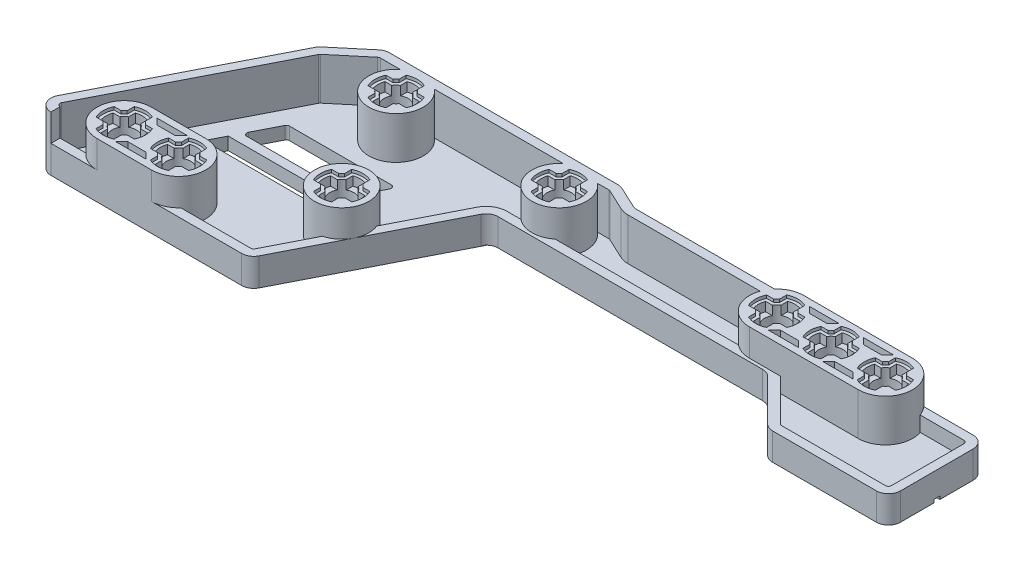
from build123d import *

# Parameters (mm, degrees)
SKETCH2_R           = 2
BOSS_EXTRUDE1_DEPTH = 9
CUT_EXTRUDE1_DEPTH  = 2
CUT_EXTRUDE3_DEPTH  = 0.5
LPATTERN1_COUNT     = 3
LPATTERN1_PITCH     = 9
CUT_EXTRUDE4_DEPTH  = 3
SKETCH6_R           = 4.5
SKETCH6_R_2         = 2
BOSS_EXTRUDE2_DEPTH = 4.5
CUT_EXTRUDE5_DEPTH  = 2
CUT_EXTRUDE6_DEPTH  = 0.5
SKETCH10_R          = 4.5
SKETCH10_R_2        = 2
BOSS_EXTRUDE3_DEPTH = 4.5
CUT_EXTRUDE7_DEPTH  = 2
CUT_EXTRUDE8_DEPTH  = 0.5
SKETCH13_R          = 4.5
SKETCH13_R_2        = 2
BOSS_EXTRUDE4_DEPTH = 4.5
CUT_EXTRUDE9_DEPTH  = 2
CUT_EXTRUDE10_DEPTH = 0.5
SKETCH16_R          = 2
BOSS_EXTRUDE5_DEPTH = 4.5
CUT_EXTRUDE11_DEPTH = 2
CUT_EXTRUDE12_DEPTH = 0.5
SKETCH19_R          = 2
BOSS_EXTRUDE6_DEPTH = 2
FILLET1_R           = 2
EXTRUDE_THIN1_DEPTH = 2.5
EXTRUDE_THIN2_DEPTH = 7
CUT_EXTRUDE13_DEPTH = 3
CUT_EXTRUDE14_DEPTH = 2
SKETCH25_R          = 2.5
CUT_EXTRUDE15_DEPTH = 0.5
CUT_EXTRUDE18_DEPTH = 0.5
FILLET2_R           = 0.5
SKETCH28_R          = 2.5
BOSS_EXTRUDE7_DEPTH = 0.1


with BuildPart() as part:
    # Sketch2 → Boss-Extrude1 (new body)
    with BuildSketch(Plane(origin=(0, 0, 0), x_dir=(1, 0, 0), z_dir=(0, 1, 0))):
        with BuildLine():
            Line((-9, 4.5), (9, 4.5))
            ThreePointArc((9, 4.5), (13.5, 0), (9, -4.5))
            Line((9, -4.5), (-9, -4.5))
            ThreePointArc((-9, -4.5), (-13.5, 0), (-9, 4.5))
        make_face()
        with Locations(Location((0, 0, 0), (0, 0, 270))):
            Circle(SKETCH2_R, mode=Mode.SUBTRACT)
        with Locations(Location((-9, 0, 0), (0, 0, 270))):
            Circle(SKETCH2_R, mode=Mode.SUBTRACT)
        with Locations(Location((9, 0, 0), (0, 0, 270))):
            Circle(SKETCH2_R, mode=Mode.SUBTRACT)
    extrude(amount=BOSS_EXTRUDE1_DEPTH)

    # Sketch3 → Cut-Extrude1 (cut)
    with BuildSketch(Plane(origin=(0, 9, 0), x_dir=(1, 0, 0), z_dir=(0, 1, 0))):
        with BuildLine():
            Line((-10.732050808, 1), (-11.828427125, 1))
            ThreePointArc((-11.828427125, 1), (-12, 0), (-11.828427125, -1))
            Line((-11.828427125, -1), (-10.732050808, -1))
            ThreePointArc((-10.732050808, -1), (-11, 0), (-10.732050808, 1))
        make_face()
        with BuildLine():
            Line((-10, -1.732050808), (-10, -2.828427125))
            ThreePointArc((-10, -2.828427125), (-9, -3), (-8, -2.828427125))
            Line((-8, -2.828427125), (-8, -1.732050808))
            ThreePointArc((-8, -1.732050808), (-9, -2), (-10, -1.732050808))
        make_face()
        with BuildLine():
            Line((-8, 1.732050808), (-8, 2.828427125))
            ThreePointArc((-8, 2.828427125), (-9, 3), (-10, 2.828427125))
            Line((-10, 2.828427125), (-10, 1.732050808))
            ThreePointArc((-10, 1.732050808), (-9, 2), (-8, 1.732050808))
        make_face()
        with BuildLine():
            Line((-7.267949192, -1), (-6.171572875, -1))
            ThreePointArc((-6.171572875, -1), (-6, 0), (-6.171572875, 1))
            Line((-6.171572875, 1), (-7.267949192, 1))
            ThreePointArc((-7.267949192, 1), (-7, 0), (-7.267949192, -1))
        make_face()
    cut_extrude1 = extrude(amount=-CUT_EXTRUDE1_DEPTH, mode=Mode.SUBTRACT)

    # Sketch4 → Cut-Extrude3 (cut)
    with BuildSketch(Plane(origin=(0, 9, 0), x_dir=(1, 0, 0), z_dir=(0, 1, 0))):
        with BuildLine():
            Line((-11, 1.5), (-12.16227766, 1.5))
            ThreePointArc((-12.16227766, 1.5), (-12.5, 0), (-12.16227766, -1.5))
            Line((-12.16227766, -1.5), (-11, -1.5))
            ThreePointArc((-11, -1.5), (-10.767766953, -1.767766953), (-10.5, -2))
            Line((-10.5, -2), (-10.5, -3.16227766))
            ThreePointArc((-10.5, -3.16227766), (-9, -3.5), (-7.5, -3.16227766))
            Line((-7.5, -3.16227766), (-7.5, -2))
            ThreePointArc((-7.5, -2), (-7.232233047, -1.767766953), (-7, -1.5))
            Line((-7, -1.5), (-5.83772234, -1.5))
            ThreePointArc((-5.83772234, -1.5), (-5.5, 0), (-5.83772234, 1.5))
            Line((-5.83772234, 1.5), (-7, 1.5))
            ThreePointArc((-7, 1.5), (-7.232233047, 1.767766953), (-7.5, 2))
            Line((-7.5, 2), (-7.5, 3.16227766))
            ThreePointArc((-7.5, 3.16227766), (-9, 3.5), (-10.5, 3.16227766))
            Line((-10.5, 3.16227766), (-10.5, 2))
            ThreePointArc((-10.5, 2), (-10.767766953, 1.767766953), (-11, 1.5))
        make_face()
    cut_extrude3 = extrude(amount=-CUT_EXTRUDE3_DEPTH, mode=Mode.SUBTRACT)

    # LPattern1: Cut-Extrude1, Cut-Extrude3 ×3
    with Locations(*[(i * LPATTERN1_PITCH, 0, 0) for i in range(1, LPATTERN1_COUNT)]):
        add(cut_extrude1, mode=Mode.SUBTRACT)
        add(cut_extrude3, mode=Mode.SUBTRACT)

    # Sketch5 → Cut-Extrude4 (cut)
    with BuildSketch(Plane(origin=(0, 9, 0), x_dir=(1, 0, 0), z_dir=(0, 1, 0))):
        Polygon((-7.003004547, 3.4), (-2.003004547, 3.4), (-3.003004547, 2.4), (-6.003004547, 2.4), align=None)
        Polygon((-3.003004547, -2.4), (-6.003004547, -2.4), (-7.003004547, -3.4), (-2.003004547, -3.4), align=None)
        Polygon((2.003004547, -3.4), (3.003004547, -2.4), (6.003004547, -2.4), (7.003004547, -3.4), align=None)
        Polygon((3.003004547, 2.4), (6.003004547, 2.4), (7.003004547, 3.4), (2.003004547, 3.4), align=None)
    extrude(amount=-CUT_EXTRUDE4_DEPTH, mode=Mode.SUBTRACT)



with BuildPart() as body_2:
    # Sketch6 → Boss-Extrude2 (new, symmetric)
    with BuildSketch(Plane(origin=(0, 4.5, 0), x_dir=(1, 0, 0), z_dir=(0, 1, 0))):
        with Locations(Location((-45, 0, 0), (0, 0, 270))):
            Circle(SKETCH6_R)
        with Locations(Location((-45, 0, 0), (0, 0, 270))):
            Circle(SKETCH6_R_2, mode=Mode.SUBTRACT)
    extrude(amount=BOSS_EXTRUDE2_DEPTH, both=True)

    # Sketch8 → Cut-Extrude5 (cut)
    with BuildSketch(Plane(origin=(0, 9, 0), x_dir=(1, 0, 0), z_dir=(0, 1, 0))):
        with BuildLine():
            Line((-44, 2.828427125), (-46, 2.828427125))
            Line((-46, 2.828427125), (-46, 1.732050808))
            ThreePointArc((-46, 1.732050808), (-45, 2), (-44, 1.732050808))
            Line((-44, 1.732050808), (-44, 2.828427125))
        make_face()
        with BuildLine():
            Line((-46, -1.732050808), (-46, -2.828427125))
            Line((-46, -2.828427125), (-44, -2.828427125))
            Line((-44, -2.828427125), (-44, -1.732050808))
            ThreePointArc((-44, -1.732050808), (-45, -2), (-46, -1.732050808))
        make_face()
        with BuildLine():
            Line((-42.171572875, -1), (-42.171572875, 1))
            Line((-42.171572875, 1), (-43.267949192, 1))
            ThreePointArc((-43.267949192, 1), (-43.068148347, 0.51763809), (-43, 0))
            ThreePointArc((-43, 0), (-43.068148347, -0.51763809), (-43.267949192, -1))
            Line((-43.267949192, -1), (-42.171572875, -1))
        make_face()
        with BuildLine():
            Line((-46.732050808, 1), (-47.828427125, 1))
            Line((-47.828427125, 1), (-47.828427125, -1))
            Line((-47.828427125, -1), (-46.732050808, -1))
            ThreePointArc((-46.732050808, -1), (-47, 0), (-46.732050808, 1))
        make_face()
        with BuildLine():
            Line((-47.828427125, -1), (-47.828427125, 1))
            ThreePointArc((-47.828427125, 1), (-48, 0), (-47.828427125, -1))
        make_face()
        with BuildLine():
            ThreePointArc((-44, 2.828427125), (-45, 3), (-46, 2.828427125))
            Line((-46, 2.828427125), (-44, 2.828427125))
        make_face()
        with BuildLine():
            ThreePointArc((-42, 0), (-42.043204321, 0.507305936), (-42.171572875, 1))
            Line((-42.171572875, 1), (-42.171572875, -1))
            ThreePointArc((-42.171572875, -1), (-42.043204321, -0.507305936), (-42, 0))
        make_face()
        with BuildLine():
            Line((-44, -2.828427125), (-46, -2.828427125))
            ThreePointArc((-46, -2.828427125), (-45, -3), (-44, -2.828427125))
        make_face()
    extrude(amount=-CUT_EXTRUDE5_DEPTH, mode=Mode.SUBTRACT)

    # Sketch9 → Cut-Extrude6 (cut)
    with BuildSketch(Plane(origin=(0, 9, 0), x_dir=(1, 0, 0), z_dir=(0, 1, 0))):
        with BuildLine():
            Line((-43, -1.5), (-41.83772234, -1.5))
            ThreePointArc((-41.83772234, -1.5), (-41.5, 0), (-41.83772234, 1.5))
            Line((-41.83772234, 1.5), (-43, 1.5))
            ThreePointArc((-43, 1.5), (-43.232233047, 1.767766953), (-43.5, 2))
            Line((-43.5, 2), (-43.5, 3.16227766))
            ThreePointArc((-43.5, 3.16227766), (-45, 3.5), (-46.5, 3.16227766))
            Line((-46.5, 3.16227766), (-46.5, 2))
            ThreePointArc((-46.5, 2), (-46.767766953, 1.767766953), (-47, 1.5))
            Line((-47, 1.5), (-48.16227766, 1.5))
            ThreePointArc((-48.16227766, 1.5), (-48.5, 0), (-48.16227766, -1.5))
            Line((-48.16227766, -1.5), (-47, -1.5))
            ThreePointArc((-47, -1.5), (-46.767766953, -1.767766953), (-46.5, -2))
            Line((-46.5, -2), (-46.5, -3.16227766))
            ThreePointArc((-46.5, -3.16227766), (-45, -3.5), (-43.5, -3.16227766))
            Line((-43.5, -3.16227766), (-43.5, -2))
            ThreePointArc((-43.5, -2), (-43.232233047, -1.767766953), (-43, -1.5))
        make_face()
    extrude(amount=-CUT_EXTRUDE6_DEPTH, mode=Mode.SUBTRACT)


with BuildPart() as body_3:
    # Sketch10 → Boss-Extrude3 (new, symmetric)
    with BuildSketch(Plane(origin=(0, 4.5, 0), x_dir=(1, 0, 0), z_dir=(0, 1, 0))):
        with Locations(Location((-72, 0, 0), (0, 0, 270))):
            Circle(SKETCH10_R)
        with Locations(Location((-72, 0, 0), (0, 0, 270))):
            Circle(SKETCH10_R_2, mode=Mode.SUBTRACT)
    extrude(amount=BOSS_EXTRUDE3_DEPTH, both=True)

    # Sketch11 → Cut-Extrude7 (cut)
    with BuildSketch(Plane(origin=(0, 9, 0), x_dir=(1, 0, 0), z_dir=(0, 1, 0))):
        with BuildLine():
            Line((-71, 2.828427125), (-73, 2.828427125))
            Line((-73, 2.828427125), (-73, 1.732050808))
            ThreePointArc((-73, 1.732050808), (-72, 2), (-71, 1.732050808))
            Line((-71, 1.732050808), (-71, 2.828427125))
        make_face()
        with BuildLine():
            ThreePointArc((-71, 2.828427125), (-72, 3), (-73, 2.828427125))
            Line((-73, 2.828427125), (-71, 2.828427125))
        make_face()
        with BuildLine():
            Line((-70.267949192, -1), (-69.171572875, -1))
            Line((-69.171572875, -1), (-69.171572875, 1))
            Line((-69.171572875, 1), (-70.267949192, 1))
            ThreePointArc((-70.267949192, 1), (-70.068148347, 0.51763809), (-70, 0))
            ThreePointArc((-70, 0), (-70.068148347, -0.51763809), (-70.267949192, -1))
        make_face()
        with BuildLine():
            Line((-69.171572875, 1), (-69.171572875, -1))
            ThreePointArc((-69.171572875, -1), (-69.043204321, -0.507305936), (-69, 0))
            ThreePointArc((-69, 0), (-69.043204321, 0.507305936), (-69.171572875, 1))
        make_face()
        with BuildLine():
            Line((-73, -1.732050808), (-73, -2.828427125))
            Line((-73, -2.828427125), (-71, -2.828427125))
            Line((-71, -2.828427125), (-71, -1.732050808))
            ThreePointArc((-71, -1.732050808), (-72, -2), (-73, -1.732050808))
        make_face()
        with BuildLine():
            Line((-71, -2.828427125), (-73, -2.828427125))
            ThreePointArc((-73, -2.828427125), (-72, -3), (-71, -2.828427125))
        make_face()
        with BuildLine():
            Line((-74.828427125, 1), (-74.828427125, -1))
            Line((-74.828427125, -1), (-73.732050808, -1))
            ThreePointArc((-73.732050808, -1), (-74, 0), (-73.732050808, 1))
            Line((-73.732050808, 1), (-74.828427125, 1))
        make_face()
        with BuildLine():
            ThreePointArc((-74.828427125, 1), (-75, 0), (-74.828427125, -1))
            Line((-74.828427125, -1), (-74.828427125, 1))
        make_face()
    extrude(amount=-CUT_EXTRUDE7_DEPTH, mode=Mode.SUBTRACT)

    # Sketch12 → Cut-Extrude8 (cut)
    with BuildSketch(Plane(origin=(0, 9, 0), x_dir=(1, 0, 0), z_dir=(0, 1, 0))):
        with BuildLine():
            Line((-75.16227766, -1.5), (-74, -1.5))
            ThreePointArc((-74, -1.5), (-73.767766953, -1.767766953), (-73.5, -2))
            Line((-73.5, -2), (-73.5, -3.16227766))
            ThreePointArc((-73.5, -3.16227766), (-72, -3.5), (-70.5, -3.16227766))
            Line((-70.5, -3.16227766), (-70.5, -2))
            ThreePointArc((-70.5, -2), (-70.232233047, -1.767766953), (-70, -1.5))
            Line((-70, -1.5), (-68.83772234, -1.5))
            ThreePointArc((-68.83772234, -1.5), (-68.5, 0), (-68.83772234, 1.5))
            Line((-68.83772234, 1.5), (-70, 1.5))
            ThreePointArc((-70, 1.5), (-70.232233047, 1.767766953), (-70.5, 2))
            Line((-70.5, 2), (-70.5, 3.16227766))
            ThreePointArc((-70.5, 3.16227766), (-72, 3.5), (-73.5, 3.16227766))
            Line((-73.5, 3.16227766), (-73.5, 2))
            ThreePointArc((-73.5, 2), (-73.767766953, 1.767766953), (-74, 1.5))
            Line((-74, 1.5), (-75.16227766, 1.5))
            ThreePointArc((-75.16227766, 1.5), (-75.5, 0), (-75.16227766, -1.5))
        make_face()
    extrude(amount=-CUT_EXTRUDE8_DEPTH, mode=Mode.SUBTRACT)


with BuildPart() as body_4:
    # Sketch13 → Boss-Extrude4 (new, symmetric)
    with BuildSketch(Plane(origin=(0, 4.5, 0), x_dir=(1, 0, 0), z_dir=(0, 1, 0))):
        with Locations(Location((-63, -18, 0), (0, 0, 270))):
            Circle(SKETCH13_R)
        with Locations(Location((-63, -18, 0), (0, 0, 270))):
            Circle(SKETCH13_R_2, mode=Mode.SUBTRACT)
    extrude(amount=BOSS_EXTRUDE4_DEPTH, both=True)

    # Sketch14 → Cut-Extrude9 (cut)
    with BuildSketch(Plane(origin=(0, 9, 0), x_dir=(1, 0, 0), z_dir=(0, 1, 0))):
        with BuildLine():
            Line((-62, -15.171572875), (-64, -15.171572875))
            Line((-64, -15.171572875), (-64, -16.267949192))
            ThreePointArc((-64, -16.267949192), (-63, -16), (-62, -16.267949192))
            Line((-62, -16.267949192), (-62, -15.171572875))
        make_face()
        with BuildLine():
            ThreePointArc((-62, -15.171572875), (-63, -15), (-64, -15.171572875))
            Line((-64, -15.171572875), (-62, -15.171572875))
        make_face()
        with BuildLine():
            Line((-61.267949192, -19), (-60.171572875, -19))
            Line((-60.171572875, -19), (-60.171572875, -17))
            Line((-60.171572875, -17), (-61.267949192, -17))
            ThreePointArc((-61.267949192, -17), (-61.068148347, -17.48236191), (-61, -18))
            ThreePointArc((-61, -18), (-61.068148347, -18.51763809), (-61.267949192, -19))
        make_face()
        with BuildLine():
            Line((-60.171572875, -17), (-60.171572875, -19))
            ThreePointArc((-60.171572875, -19), (-60.043204321, -18.507305936), (-60, -18))
            ThreePointArc((-60, -18), (-60.043204321, -17.492694064), (-60.171572875, -17))
        make_face()
        with BuildLine():
            Line((-64, -19.732050808), (-64, -20.828427125))
            Line((-64, -20.828427125), (-62, -20.828427125))
            Line((-62, -20.828427125), (-62, -19.732050808))
            ThreePointArc((-62, -19.732050808), (-63, -20), (-64, -19.732050808))
        make_face()
        with BuildLine():
            Line((-62, -20.828427125), (-64, -20.828427125))
            ThreePointArc((-64, -20.828427125), (-63, -21), (-62, -20.828427125))
        make_face()
        with BuildLine():
            Line((-65.828427125, -17), (-65.828427125, -19))
            Line((-65.828427125, -19), (-64.732050808, -19))
            ThreePointArc((-64.732050808, -19), (-65, -18), (-64.732050808, -17))
            Line((-64.732050808, -17), (-65.828427125, -17))
        make_face()
        with BuildLine():
            ThreePointArc((-65.828427125, -17), (-66, -18), (-65.828427125, -19))
            Line((-65.828427125, -19), (-65.828427125, -17))
        make_face()
    extrude(amount=-CUT_EXTRUDE9_DEPTH, mode=Mode.SUBTRACT)

    # Sketch15 → Cut-Extrude10 (cut)
    with BuildSketch(Plane(origin=(0, 9, 0), x_dir=(1, 0, 0), z_dir=(0, 1, 0))):
        with BuildLine():
            Line((-59.83772234, -16.5), (-61, -16.5))
            ThreePointArc((-61, -16.5), (-61.232233047, -16.232233047), (-61.5, -16))
            Line((-61.5, -16), (-61.5, -14.83772234))
            ThreePointArc((-61.5, -14.83772234), (-63, -14.5), (-64.5, -14.83772234))
            Line((-64.5, -14.83772234), (-64.5, -16))
            ThreePointArc((-64.5, -16), (-64.767766953, -16.232233047), (-65, -16.5))
            Line((-65, -16.5), (-66.16227766, -16.5))
            ThreePointArc((-66.16227766, -16.5), (-66.5, -18), (-66.16227766, -19.5))
            Line((-66.16227766, -19.5), (-65, -19.5))
            ThreePointArc((-65, -19.5), (-64.767766953, -19.767766953), (-64.5, -20))
            Line((-64.5, -20), (-64.5, -21.16227766))
            ThreePointArc((-64.5, -21.16227766), (-63, -21.5), (-61.5, -21.16227766))
            Line((-61.5, -21.16227766), (-61.5, -20))
            ThreePointArc((-61.5, -20), (-61.232233047, -19.767766953), (-61, -19.5))
            Line((-61, -19.5), (-59.83772234, -19.5))
            ThreePointArc((-59.83772234, -19.5), (-59.5, -18), (-59.83772234, -16.5))
        make_face()
    extrude(amount=-CUT_EXTRUDE10_DEPTH, mode=Mode.SUBTRACT)


with BuildPart() as body_5:
    # Sketch16 → Boss-Extrude5 (new, symmetric)
    with BuildSketch(Plane(origin=(0, 4.5, 0), x_dir=(1, 0, 0), z_dir=(0, 1, 0))):
        with BuildLine():
            Line((-90, -22.5), (-81, -22.5))
            ThreePointArc((-81, -22.5), (-76.5, -27), (-81, -31.5))
            Line((-81, -31.5), (-90, -31.5))
            ThreePointArc((-90, -31.5), (-94.5, -27), (-90, -22.5))
        make_face()
        with Locations(Location((-90, -27, 0), (0, 0, 270))):
            Circle(SKETCH16_R, mode=Mode.SUBTRACT)
        with Locations(Location((-81, -27, 0), (0, 0, 270))):
            Circle(SKETCH16_R, mode=Mode.SUBTRACT)
    extrude(amount=BOSS_EXTRUDE5_DEPTH, both=True)

    # Sketch17 → Cut-Extrude11 (cut)
    with BuildSketch(Plane(origin=(0, 9, 0), x_dir=(1, 0, 0), z_dir=(0, 1, 0))):
        with BuildLine():
            Line((-82, -29.828427125), (-80, -29.828427125))
            Line((-80, -29.828427125), (-80, -28.732050808))
            ThreePointArc((-80, -28.732050808), (-81, -29), (-82, -28.732050808))
            Line((-82, -28.732050808), (-82, -29.828427125))
        make_face()
        with BuildLine():
            ThreePointArc((-82, -29.828427125), (-81, -30), (-80, -29.828427125))
            Line((-80, -29.828427125), (-82, -29.828427125))
        make_face()
        with BuildLine():
            Line((-82.732050808, -26), (-83.828427125, -26))
            Line((-83.828427125, -26), (-83.828427125, -28))
            Line((-83.828427125, -28), (-82.732050808, -28))
            ThreePointArc((-82.732050808, -28), (-83, -27), (-82.732050808, -26))
        make_face()
        with BuildLine():
            Line((-83.828427125, -28), (-83.828427125, -26))
            ThreePointArc((-83.828427125, -26), (-84, -27), (-83.828427125, -28))
        make_face()
        with BuildLine():
            Line((-78.171572875, -28), (-78.171572875, -26))
            Line((-78.171572875, -26), (-79.267949192, -26))
            ThreePointArc((-79.267949192, -26), (-79.068148347, -26.48236191), (-79, -27))
            ThreePointArc((-79, -27), (-79.068148347, -27.51763809), (-79.267949192, -28))
            Line((-79.267949192, -28), (-78.171572875, -28))
        make_face()
        with BuildLine():
            ThreePointArc((-78, -27), (-78.043204321, -26.492694064), (-78.171572875, -26))
            Line((-78.171572875, -26), (-78.171572875, -28))
            ThreePointArc((-78.171572875, -28), (-78.043204321, -27.507305936), (-78, -27))
        make_face()
        with BuildLine():
            Line((-80, -25.267949192), (-80, -24.171572875))
            Line((-80, -24.171572875), (-82, -24.171572875))
            Line((-82, -24.171572875), (-82, -25.267949192))
            ThreePointArc((-82, -25.267949192), (-81, -25), (-80, -25.267949192))
        make_face()
        with BuildLine():
            Line((-82, -24.171572875), (-80, -24.171572875))
            ThreePointArc((-80, -24.171572875), (-81, -24), (-82, -24.171572875))
        make_face()
        with BuildLine():
            Line((-88.267949192, -28), (-87.171572875, -28))
            Line((-87.171572875, -28), (-87.171572875, -26))
            Line((-87.171572875, -26), (-88.267949192, -26))
            ThreePointArc((-88.267949192, -26), (-88.068148347, -26.48236191), (-88, -27))
            ThreePointArc((-88, -27), (-88.068148347, -27.51763809), (-88.267949192, -28))
        make_face()
        with BuildLine():
            Line((-87.171572875, -26), (-87.171572875, -28))
            ThreePointArc((-87.171572875, -28), (-87.043204321, -27.507305936), (-87, -27))
            ThreePointArc((-87, -27), (-87.043204321, -26.492694064), (-87.171572875, -26))
        make_face()
        with BuildLine():
            Line((-91, -28.732050808), (-91, -29.828427125))
            Line((-91, -29.828427125), (-89, -29.828427125))
            Line((-89, -29.828427125), (-89, -28.732050808))
            ThreePointArc((-89, -28.732050808), (-90, -29), (-91, -28.732050808))
        make_face()
        with BuildLine():
            Line((-89, -29.828427125), (-91, -29.828427125))
            ThreePointArc((-91, -29.828427125), (-90, -30), (-89, -29.828427125))
        make_face()
        with BuildLine():
            Line((-92.828427125, -26), (-92.828427125, -28))
            Line((-92.828427125, -28), (-91.732050808, -28))
            ThreePointArc((-91.732050808, -28), (-92, -27), (-91.732050808, -26))
            Line((-91.732050808, -26), (-92.828427125, -26))
        make_face()
        with BuildLine():
            ThreePointArc((-92.828427125, -26), (-93, -27), (-92.828427125, -28))
            Line((-92.828427125, -28), (-92.828427125, -26))
        make_face()
        with BuildLine():
            Line((-89, -24.171572875), (-91, -24.171572875))
            Line((-91, -24.171572875), (-91, -25.267949192))
            ThreePointArc((-91, -25.267949192), (-90, -25), (-89, -25.267949192))
            Line((-89, -25.267949192), (-89, -24.171572875))
        make_face()
        with BuildLine():
            ThreePointArc((-89, -24.171572875), (-90, -24), (-91, -24.171572875))
            Line((-91, -24.171572875), (-89, -24.171572875))
        make_face()
    extrude(amount=-CUT_EXTRUDE11_DEPTH, mode=Mode.SUBTRACT)

    # Sketch18 → Cut-Extrude12 (cut)
    with BuildSketch(Plane(origin=(0, 9, 0), x_dir=(1, 0, 0), z_dir=(0, 1, 0))):
        with BuildLine():
            Line((-84.16227766, -25.5), (-83, -25.5))
            ThreePointArc((-83, -25.5), (-82.767766953, -25.232233047), (-82.5, -25))
            Line((-82.5, -25), (-82.5, -23.83772234))
            ThreePointArc((-82.5, -23.83772234), (-81, -23.5), (-79.5, -23.83772234))
            Line((-79.5, -23.83772234), (-79.5, -25))
            ThreePointArc((-79.5, -25), (-79.232233047, -25.232233047), (-79, -25.5))
            Line((-79, -25.5), (-77.83772234, -25.5))
            ThreePointArc((-77.83772234, -25.5), (-77.5, -27), (-77.83772234, -28.5))
            Line((-77.83772234, -28.5), (-79, -28.5))
            ThreePointArc((-79, -28.5), (-79.232233047, -28.767766953), (-79.5, -29))
            Line((-79.5, -29), (-79.5, -30.16227766))
            ThreePointArc((-79.5, -30.16227766), (-81, -30.5), (-82.5, -30.16227766))
            Line((-82.5, -30.16227766), (-82.5, -29))
            ThreePointArc((-82.5, -29), (-82.767766953, -28.767766953), (-83, -28.5))
            Line((-83, -28.5), (-84.16227766, -28.5))
            ThreePointArc((-84.16227766, -28.5), (-84.5, -27), (-84.16227766, -25.5))
        make_face()
        with BuildLine():
            Line((-88.5, -25), (-88.5, -23.83772234))
            ThreePointArc((-88.5, -23.83772234), (-90, -23.5), (-91.5, -23.83772234))
            Line((-91.5, -23.83772234), (-91.5, -25))
            ThreePointArc((-91.5, -25), (-91.767766953, -25.232233047), (-92, -25.5))
            Line((-92, -25.5), (-93.16227766, -25.5))
            ThreePointArc((-93.16227766, -25.5), (-93.5, -27), (-93.16227766, -28.5))
            Line((-93.16227766, -28.5), (-92, -28.5))
            ThreePointArc((-92, -28.5), (-91.767766953, -28.767766953), (-91.5, -29))
            Line((-91.5, -29), (-91.5, -30.16227766))
            ThreePointArc((-91.5, -30.16227766), (-90, -30.5), (-88.5, -30.16227766))
            Line((-88.5, -30.16227766), (-88.5, -29))
            ThreePointArc((-88.5, -29), (-88.232233047, -28.767766953), (-88, -28.5))
            Line((-88, -28.5), (-86.83772234, -28.5))
            ThreePointArc((-86.83772234, -28.5), (-86.5, -27), (-86.83772234, -25.5))
            Line((-86.83772234, -25.5), (-88, -25.5))
            ThreePointArc((-88, -25.5), (-88.232233047, -25.232233047), (-88.5, -25))
        make_face()
    extrude(amount=-CUT_EXTRUDE12_DEPTH, mode=Mode.SUBTRACT)


with BuildPart() as part_1:
    add(part.part)

    add(body_2.part)  # Boss-Extrude6 merges body 2

    add(body_3.part)  # Boss-Extrude6 merges body 3

    add(body_4.part)  # Boss-Extrude6 merges body 4

    add(body_5.part)  # Boss-Extrude6 merges body 5
    # Sketch19 → Boss-Extrude6 (add)
    with BuildSketch(Plane(origin=(0, 0, 0), x_dir=(1, 0, 0), z_dir=(0, 1, 0))):
        with BuildLine():
            Line((9, 4.5), (-9, 4.5))
            ThreePointArc((-9, 4.5), (-10.837117307, 4.107919181), (-12.354101966, 3))
            Line((-12.354101966, 3), (-35.552331226, 3))
            Line((-35.552331226, 3), (-39.841345067, 5))
            Line((-39.841345067, 5), (-78.841345067, 5))
            Line((-78.841345067, 5), (-84.863414396, -0.053116153))
            Line((-84.863414396, -0.053116153), (-100.886402024, -31.5))
            Line((-100.886402024, -31.5), (-64.828125499, -31.5))
            Line((-64.828125499, -31.5), (-51.325701087, -5))
            Line((-51.325701087, -5), (-5.5, -5))
            Line((-5.5, -5), (2.5, -13))
            Line((2.5, -13), (22.5, -13))
            Line((22.5, -13), (22.5, 3))
            Line((22.5, 3), (12.354101966, 3))
            ThreePointArc((12.354101966, 3), (10.837117307, 4.107919181), (9, 4.5))
        make_face()
        with Locations(Location((-90, -27, 0), (0, 0, 120))):
            Circle(SKETCH19_R, mode=Mode.SUBTRACT)
        with Locations(Location((-81, -27, 0), (0, 0, 60))):
            Circle(SKETCH19_R, mode=Mode.SUBTRACT)
        with Locations(Location((-63, -18, 0), (0, 0, 120))):
            Circle(SKETCH19_R, mode=Mode.SUBTRACT)
        with Locations(Location((-72, 0, 0), (0, 0, 120))):
            Circle(SKETCH19_R, mode=Mode.SUBTRACT)
        with Locations(Location((-45, 0, 0), (0, 0, 120))):
            Circle(SKETCH19_R, mode=Mode.SUBTRACT)
        with Locations(Location((-9, 0, 0), (0, 0, 120))):
            Circle(SKETCH19_R, mode=Mode.SUBTRACT)
        with Locations(Location((0, 0, 0), (0, 0, 120))):
            Circle(SKETCH19_R, mode=Mode.SUBTRACT)
        with Locations(Location((9, 0, 0), (0, 0, 120))):
            Circle(SKETCH19_R, mode=Mode.SUBTRACT)
    extrude(amount=BOSS_EXTRUDE6_DEPTH)

    # Fillet1
    fillet1_edges = [part_1.edges().sort_by_distance(p)[0] for p in [
        (-35.552331226, 1, -3),
        (-39.841345067, 1, -5),
        (-78.841345067, 1, -5),
        (-84.863414396, 1, 0.053116153),
        (-100.886402024, 1, 31.5),
        (-64.828125499, 1, 31.5),
        (-51.325701087, 1, 5),
        (-5.5, 1, 5),
        (2.5, 1, 13),
        (22.5, 1, 13),
        (22.5, 1, -3),
    ]]
    fillet(fillet1_edges, radius=FILLET1_R)

    # Sketch20 → Extrude-Thin1 (add)
    with BuildSketch(Plane(origin=(0, 2, 0), x_dir=(1, 0, 0), z_dir=(0, 1, 0))):
        with BuildLine():
            Line((-97.622698649, -31.5), (-90, -31.5))
            Line((-90, -31.5), (-81, -31.5))
            Line((-81, -31.5), (-66.053727075, -31.5))
            ThreePointArc((-66.053727075, -31.5), (-65.008729946, -31.205280329), (-64.271714027, -30.407980999))
            Line((-64.271714027, -30.407980999), (-58.990470641, -20.042957249))
            Line((-58.990470641, -20.042957249), (-51.882112559, -6.092019001))
            ThreePointArc((-51.882112559, -6.092019001), (-51.14509664, -5.294719671), (-50.100099511, -5))
            Line((-50.100099511, -5), (-6.328427125, -5))
            ThreePointArc((-6.328427125, -5), (-5.56306026, -5.152240935), (-4.914213562, -5.585786438))
            Line((-4.914213562, -5.585786438), (1.914213562, -12.414213562))
            ThreePointArc((1.914213562, -12.414213562), (2.56306026, -12.847759065), (3.328427125, -13))
            Line((3.328427125, -13), (20.5, -13))
            ThreePointArc((20.5, -13), (21.914213562, -12.414213562), (22.5, -11))
            Line((22.5, -11), (22.5, 1))
            ThreePointArc((22.5, 1), (21.914213562, 2.414213562), (20.5, 3))
            Line((20.5, 3), (12.354101966, 3))
            Line((12.354101966, 3), (12.354101966, 1.5))
            Line((12.354101966, 1.5), (20.5, 1.5))
            ThreePointArc((20.5, 1.5), (20.853553391, 1.353553391), (21, 1))
            Line((21, 1), (21, -11))
            ThreePointArc((21, -11), (20.853553391, -11.353553391), (20.5, -11.5))
            Line((20.5, -11.5), (3.328427125, -11.5))
            ThreePointArc((3.328427125, -11.5), (3.137085409, -11.461939766), (2.974873734, -11.353553391))
            Line((2.974873734, -11.353553391), (-3.853553391, -4.525126266))
            ThreePointArc((-3.853553391, -4.525126266), (-4.989035111, -3.766421636), (-6.328427125, -3.5))
            Line((-6.328427125, -3.5), (-50.100099511, -3.5))
            ThreePointArc((-50.100099511, -3.5), (-51.928844487, -4.015759425), (-53.218622346, -5.411033251))
            Line((-53.218622346, -5.411033251), (-60.326980427, -19.361971499))
            Line((-60.326980427, -19.361971499), (-65.608223813, -29.72699525))
            ThreePointArc((-65.608223813, -29.72699525), (-65.792477793, -29.926320082), (-66.053727075, -30))
            Line((-66.053727075, -30), (-81, -30))
            Line((-81, -30), (-90, -30))
            Line((-90, -30), (-97.622698649, -30))
            Line((-97.622698649, -30), (-97.622698649, -31.5))
        make_face()
    extrude(amount=EXTRUDE_THIN1_DEPTH)

    # Sketch21 → Extrude-Thin2 (add)
    with BuildSketch(Plane(origin=(0, 2, 0), x_dir=(1, 0, 0), z_dir=(0, 1, 0))):
        with BuildLine():
            Line((-12.354101966, 3), (-35.108941901, 3))
            ThreePointArc((-35.108941901, 3), (-35.541821129, 3.047407986), (-35.954178424, 3.187384426))
            Line((-35.954178424, 3.187384426), (-39.439497869, 4.812615574))
            ThreePointArc((-39.439497869, 4.812615574), (-39.851855165, 4.952592014), (-40.284734393, 5))
            Line((-40.284734393, 5), (-78.113404599, 5))
            ThreePointArc((-78.113404599, 5), (-78.797444885, 4.879385242), (-79.398979818, 4.532088886))
            Line((-79.398979818, 4.532088886), (-84.551707389, 0.208437082))
            ThreePointArc((-84.551707389, 0.208437082), (-84.831348484, -0.078622531), (-85.048145218, -0.415670805))
            Line((-85.048145218, -0.415670805), (-99.404711698, -28.592019001))
            ThreePointArc((-99.404711698, -28.592019001), (-99.327978978, -30.544997129), (-97.622698649, -31.5))
            Line((-97.622698649, -31.5), (-97.622698649, -30))
            ThreePointArc((-97.622698649, -30), (-98.049018732, -29.761249282), (-98.068201911, -29.27300475))
            Line((-98.068201911, -29.27300475), (-83.711635432, -1.096656555))
            ThreePointArc((-83.711635432, -1.096656555), (-83.657436248, -1.012394486), (-83.587525975, -0.940629583))
            Line((-83.587525975, -0.940629583), (-78.434798404, 3.383022222))
            ThreePointArc((-78.434798404, 3.383022222), (-78.28441467, 3.46984631), (-78.113404599, 3.5))
            Line((-78.113404599, 3.5), (-40.284734393, 3.5))
            ThreePointArc((-40.284734393, 3.5), (-40.176514586, 3.488148004), (-40.073425262, 3.453153894))
            Line((-40.073425262, 3.453153894), (-36.588105817, 1.827922745))
            ThreePointArc((-36.588105817, 1.827922745), (-35.86648055, 1.582963975), (-35.108941901, 1.5))
            Line((-35.108941901, 1.5), (-12.354101966, 1.5))
            Line((-12.354101966, 1.5), (-12.354101966, 3))
        make_face()
    extrude(amount=EXTRUDE_THIN2_DEPTH)

    # Sketch22 → Cut-Extrude13 (cut)
    with BuildSketch(Plane(origin=(0, 9, 0), x_dir=(1, 0, 0), z_dir=(0, 1, 0))):
        Polygon((-88, -23.6), (-87, -24.6), (-84, -24.6), (-83, -23.6), align=None)
        Polygon((-83, -30.4), (-88, -30.4), (-87, -29.4), (-84, -29.4), align=None)
    extrude(amount=-CUT_EXTRUDE13_DEPTH, mode=Mode.SUBTRACT)

    # Sketch23 → Cut-Extrude14 (cut)
    with BuildSketch(Plane(origin=(0, 2, 0), x_dir=(1, 0, 0), z_dir=(0, 1, 0))):
        Polygon((-86.5, -13.284023179), (-87.861971499, -15.957042751), (-69.861971499, -15.957042751), (-68.5, -13.284023179), align=None)
        with BuildLine():
            Line((-84.919785982, -11.784023179), (-68.04211222, -11.784023179))
            ThreePointArc((-68.04211222, -11.784023179), (-67.780862937, -11.710343261), (-67.596608958, -11.511018428))
            Line((-67.596608958, -11.511018428), (-65.55850716, -7.511018428))
            ThreePointArc((-65.55850716, -7.511018428), (-65.57769034, -7.022773896), (-66.004010422, -6.784023179))
            Line((-66.004010422, -6.784023179), (-82.881684184, -6.784023179))
            ThreePointArc((-82.881684184, -6.784023179), (-83.142933467, -6.857703096), (-83.327187446, -7.057027929))
            Line((-83.327187446, -7.057027929), (-85.365289244, -11.057027929))
            ThreePointArc((-85.365289244, -11.057027929), (-85.346106064, -11.545272461), (-84.919785982, -11.784023179))
        make_face()
    extrude(amount=-CUT_EXTRUDE14_DEPTH, mode=Mode.SUBTRACT)

    # Sketch25 → Cut-Extrude15 (cut)
    with BuildSketch(Plane.XZ):
        with Locations(Location((-81, 27, 0), (0, 0, 270))):
            Circle(SKETCH25_R)
        with Locations(Location((-90, 27, 0), (0, 0, 270))):
            Circle(SKETCH25_R)
        with Locations(Location((-63, 18, 0), (0, 0, 270))):
            Circle(SKETCH25_R)
        with Locations(Location((-72, 0, 0), (0, 0, 270))):
            Circle(SKETCH25_R)
        with Locations(Location((-45, 0, 0), (0, 0, 270))):
            Circle(SKETCH25_R)
        with Locations(Location((-9, 0, 0), (0, 0, 270))):
            Circle(SKETCH25_R)
        with Locations(Location((0, 0, 0), (0, 0, 270))):
            Circle(SKETCH25_R)
        with Locations(Location((9, 0, 0), (0, 0, 270))):
            Circle(SKETCH25_R)
    extrude(amount=-CUT_EXTRUDE15_DEPTH, mode=Mode.SUBTRACT)

    # Sketch27 → Cut-Extrude18 (cut)
    with BuildSketch(Plane.XZ):
        Polygon((22.5, 4.500641581), (-2.594496704, 4.500641581), (-4.095138284, 3), (-49.101725268, 3), (-49.101725268, 4), (-4.509351847, 4), (-3.009993428, 5.499358419), (22.5, 5.499358419), align=None)
    extrude(amount=-CUT_EXTRUDE18_DEPTH, mode=Mode.SUBTRACT)

    # Fillet2
    fillet2_edges = [part_1.edges().sort_by_distance(p)[0] for p in [
        (-2.594496704, 0.25, 4.500641581),
        (-4.095138284, 0.25, 3),
        (-4.509351847, 0.25, 4),
        (-3.009993428, 0.25, 5.499358419),
    ]]
    fillet(fillet2_edges, radius=FILLET2_R)

    # Sketch28 → Boss-Extrude7 (add)
    with BuildSketch(Plane.XZ):
        with BuildLine():
            Line((-50.77807384, -5), (-78.113404599, -5))
            ThreePointArc((-78.113404599, -5), (-78.797444885, -4.879385242), (-79.398979818, -4.532088886))
            Line((-79.398979818, -4.532088886), (-84.551707389, -0.208437082))
            ThreePointArc((-84.551707389, -0.208437082), (-84.831348484, 0.078622531), (-85.048145218, 0.415670805))
            Line((-85.048145218, 0.415670805), (-99.404711698, 28.592019001))
            ThreePointArc((-99.404711698, 28.592019001), (-99.327978978, 30.544997129), (-97.622698649, 31.5))
            Line((-97.622698649, 31.5), (-66.053727075, 31.5))
            ThreePointArc((-66.053727075, 31.5), (-65.008729946, 31.205280329), (-64.271714027, 30.407980999))
            Line((-64.271714027, 30.407980999), (-51.882112559, 6.092019001))
            Line((-51.882112559, 6.092019001), (-48.996060791, 0.427823481))
            ThreePointArc((-48.996060791, 0.427823481), (-48.833333999, -0.01326679), (-48.77807384, -0.480157518))
            Line((-48.77807384, -0.480157518), (-48.77807384, -3))
            ThreePointArc((-48.77807384, -3), (-49.363860277, -4.414213562), (-50.77807384, -5))
        make_face()
        with Locations(Location((-90, 27, 0), (0, 0, 270))):
            Circle(SKETCH28_R, mode=Mode.SUBTRACT)
        with Locations(Location((-81, 27, 0), (0, 0, 270))):
            Circle(SKETCH28_R, mode=Mode.SUBTRACT)
        with Locations(Location((-72, 0, 0), (0, 0, 270))):
            Circle(SKETCH28_R, mode=Mode.SUBTRACT)
        with Locations(Location((-63, 18, 0), (0, 0, 270))):
            Circle(SKETCH28_R, mode=Mode.SUBTRACT)
        with BuildLine():
            Line((-85.365289244, 11.057027929), (-83.327187446, 7.057027929))
            ThreePointArc((-83.327187446, 7.057027929), (-83.142933467, 6.857703096), (-82.881684184, 6.784023179))
            Line((-82.881684184, 6.784023179), (-66.004010422, 6.784023179))
            ThreePointArc((-66.004010422, 6.784023179), (-65.57769034, 7.022773896), (-65.55850716, 7.511018428))
            Line((-65.55850716, 7.511018428), (-67.596608958, 11.511018428))
            ThreePointArc((-67.596608958, 11.511018428), (-67.780862937, 11.710343261), (-68.04211222, 11.784023179))
            Line((-68.04211222, 11.784023179), (-84.919785982, 11.784023179))
            ThreePointArc((-84.919785982, 11.784023179), (-85.346106064, 11.545272461), (-85.365289244, 11.057027929))
        make_face(mode=Mode.SUBTRACT)
        Polygon((-87.861971499, 15.957042751), (-86.5, 13.284023179), (-68.5, 13.284023179), (-69.861971499, 15.957042751), align=None, mode=Mode.SUBTRACT)
    extrude(amount=BOSS_EXTRUDE7_DEPTH)


solid = part_1.part
